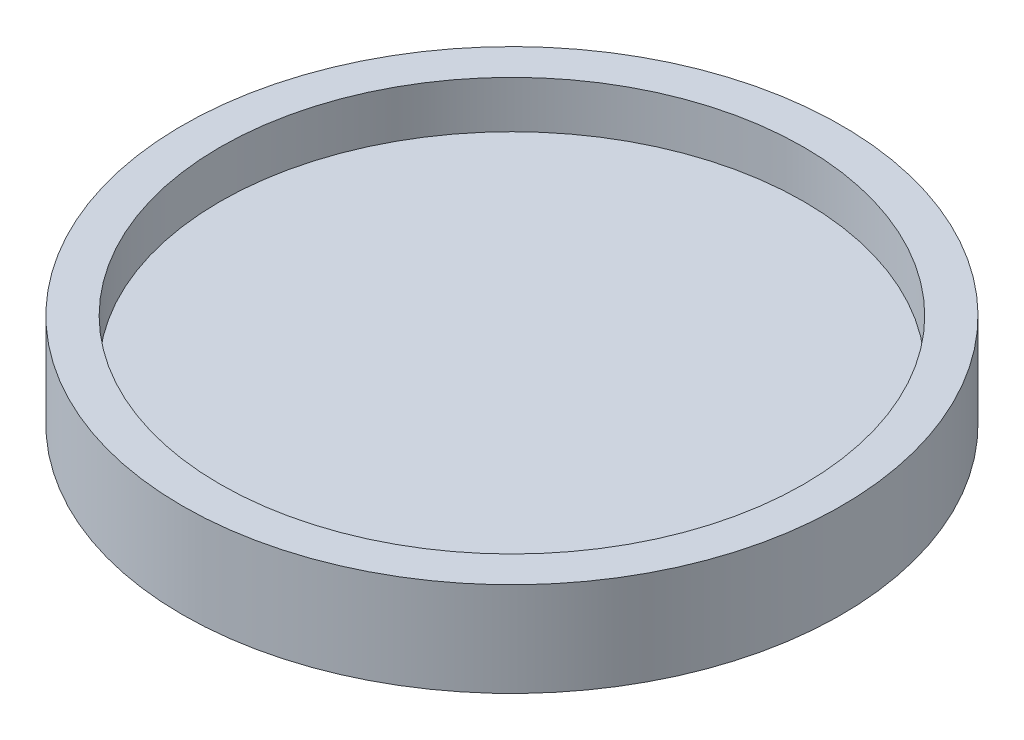
from build123d import *

# Parameters (mm, degrees)
SKETCH1_R           = 35
BOSS_EXTRUDE2_DEPTH = 10
SKETCH2_R           = 31
CUT_EXTRUDE1_DEPTH  = 5
SKETCH3_R           = 1.5
BOSS_EXTRUDE3_DEPTH = 5


with BuildPart() as part:
    # Sketch1 → Boss-Extrude2 (new body)
    with BuildSketch(Plane(origin=(0, 0, 0), x_dir=(1, 0, 0), z_dir=(0, 1, 0))):
        Circle(SKETCH1_R)
    extrude(amount=BOSS_EXTRUDE2_DEPTH)

    # Sketch2 → Cut-Extrude1 (cut)
    with BuildSketch(Plane(origin=(0, 10, 0), x_dir=(1, 0, 0), z_dir=(0, 1, 0))):
        Circle(SKETCH2_R)
    extrude(amount=-CUT_EXTRUDE1_DEPTH, mode=Mode.SUBTRACT)

    # Sketch3 → Boss-Extrude3 (add)
    with BuildSketch(Plane.XZ):
        Circle(SKETCH3_R)
    extrude(amount=BOSS_EXTRUDE3_DEPTH)


solid = part.part
